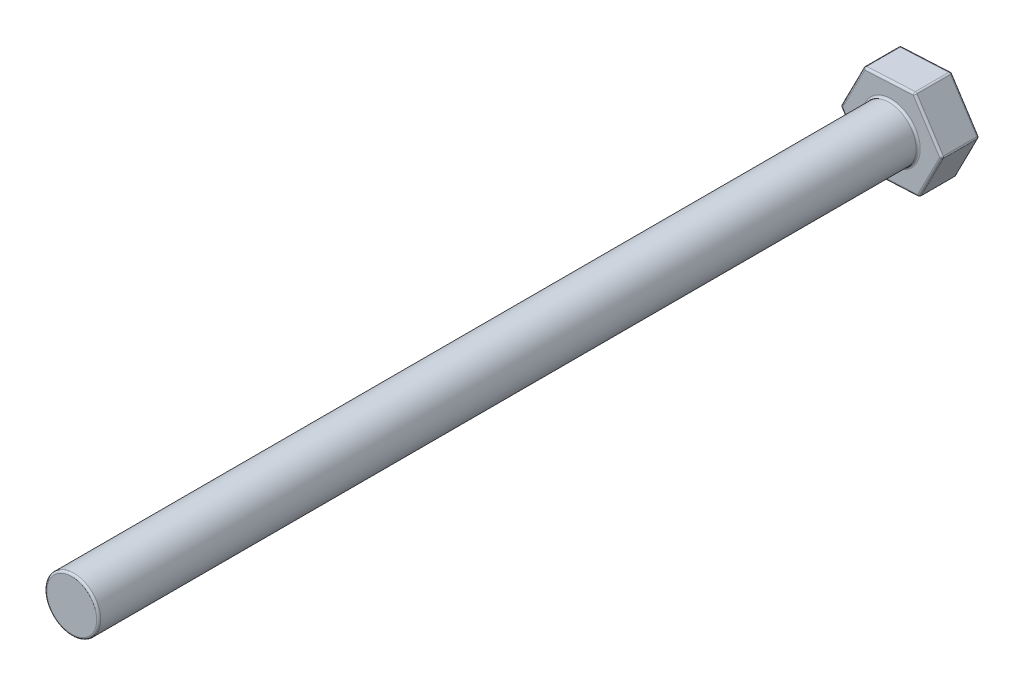
from build123d import *

# Parameters (mm, degrees)
SKETCH_1_R      = 3.95
EXTRUDE_1_DEPTH = 120
EXTRUDE_2_DEPTH = 5.5
FILLET_1_R      = 0.3


with BuildPart() as part:
    # Эскиз1 → Бобышка-Вытянуть1 (new body)
    with BuildSketch(Plane.XY):
        Circle(SKETCH_1_R)
    extrude(amount=EXTRUDE_1_DEPTH)

    # Эскиз2 → Бобышка-Вытянуть2 (add)
    with BuildSketch(Plane(origin=(0, 0, 0), x_dir=(-1, 0, 0), z_dir=(0, 0, -1))):
        Polygon((-7.438440775, 0.373629267), (-4.042792825, -6.255064042), (3.395647951, -6.62869331), (7.438440775, -0.373629267), (4.042792825, 6.255064042), (-3.395647951, 6.62869331), align=None)
    extrude(amount=EXTRUDE_2_DEPTH)

    # Скругление1
    fillet_1_edges = [part.edges().sort_by_distance(p)[0] for p in [
        (-3.95, 0, 120),
        (-3.95, 0, 0),
        (5.417044363, 3.501161289, 0),
        (3.395647951, 6.62869331, -2.75),
        (5.7406168, -2.940717387, 0),
        (7.438440775, 0.373629267, -2.75),
        (0.323572437, -6.441878676, 0),
        (4.042792825, -6.255064042, -2.75),
        (-5.417044363, -3.501161289, 0),
        (-3.395647951, -6.62869331, -2.75),
        (-5.7406168, 2.940717387, 0),
        (-7.438440775, -0.373629267, -2.75),
        (-0.323572437, 6.441878676, 0),
        (-4.042792825, 6.255064042, -2.75),
        (5.417044363, 3.501161289, -5.5),
        (5.7406168, -2.940717387, -5.5),
        (0.323572437, -6.441878676, -5.5),
        (-5.417044363, -3.501161289, -5.5),
        (-5.7406168, 2.940717387, -5.5),
        (-0.323572437, 6.441878676, -5.5),
    ]]
    fillet(fillet_1_edges, radius=FILLET_1_R)


solid = part.part
